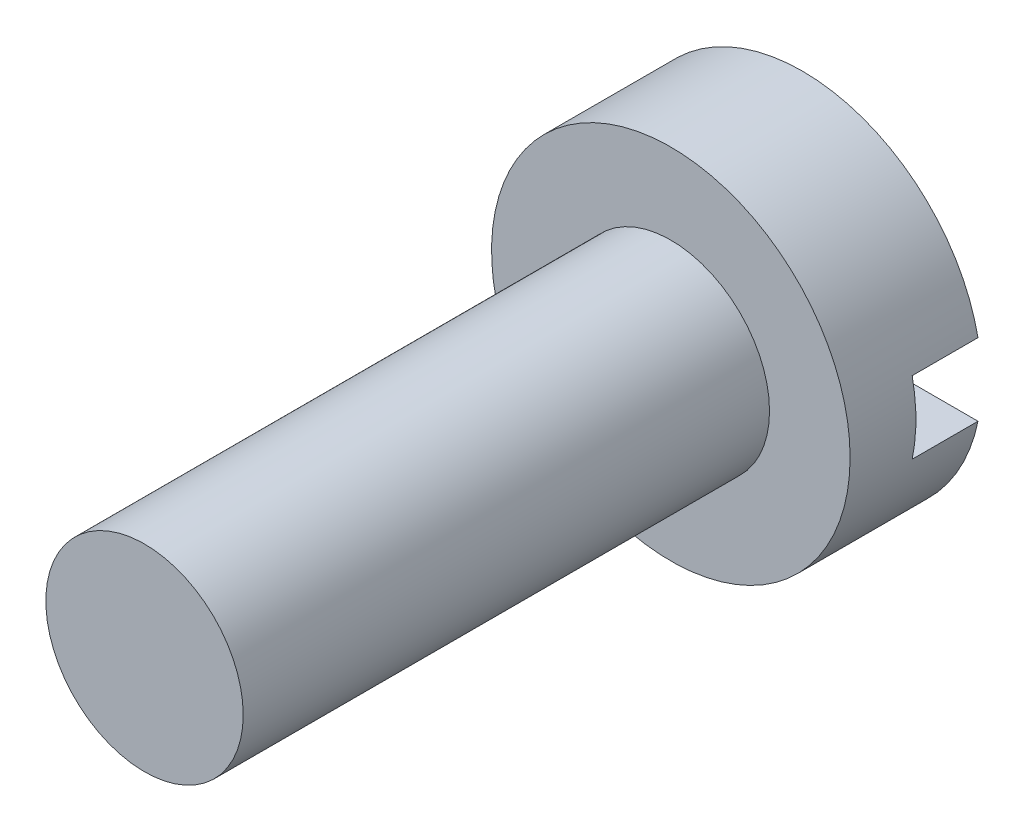
from build123d import *

# Parameters (mm, degrees)
SKETCH1_R          = 2.725
EXTRUDE1_DEPTH     = 2
CUT_EXTRUDE1_DEPTH = 1
SKETCH3_R          = 1.5
EXTRUDE2_DEPTH     = 8


with BuildPart() as part:
    # Sketch1 → Extrude1 (new body)
    with BuildSketch(Plane.XY):
        Circle(SKETCH1_R)
    extrude(amount=EXTRUDE1_DEPTH)

    # Sketch2 → Cut-Extrude1 (cut)
    with BuildSketch(Plane(origin=(0, 0, 0), x_dir=(-1, 0, 0), z_dir=(0, 0, -1))):
        Polygon((3.449801909, 0), (3.449801909, 0.55), (-3.901269584, 0.55), (-3.901269584, -0.55), (3.449801909, -0.55), align=None)
    extrude(amount=-CUT_EXTRUDE1_DEPTH, mode=Mode.SUBTRACT)

    # Sketch3 → Extrude2 (add)
    with BuildSketch(Plane.XY.offset(2)):
        Circle(SKETCH3_R)
    extrude(amount=EXTRUDE2_DEPTH)


solid = part.part
